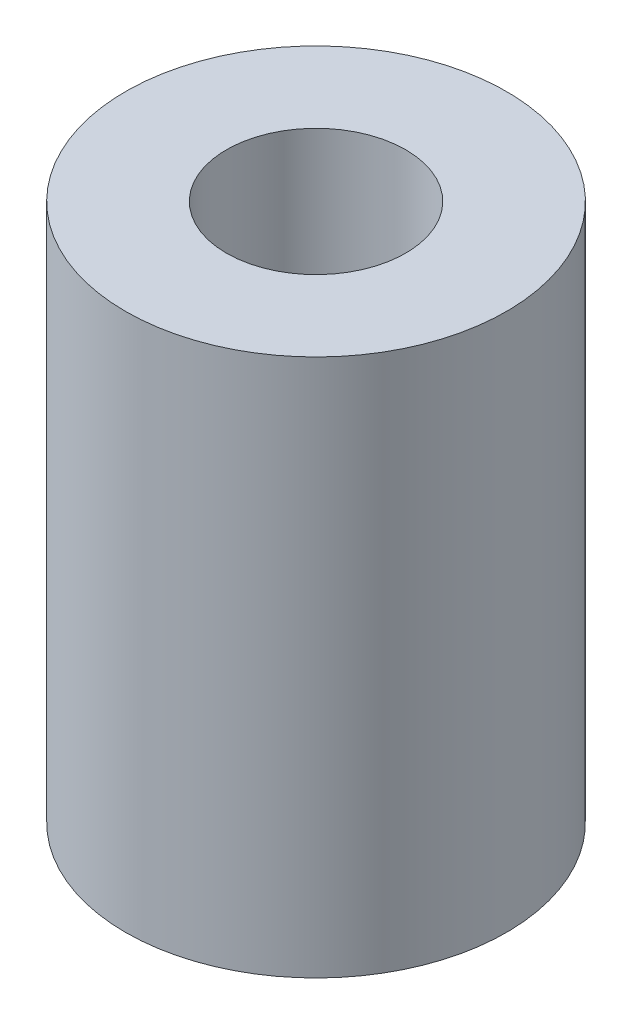
from build123d import *

# Parameters (mm, degrees)
SKETCH1_R           = 2.125
SKETCH1_R_2         = 1
BOSS_EXTRUDE1_DEPTH = 6


with BuildPart() as part:
    # Sketch1 → Boss-Extrude1 (new body)
    with BuildSketch(Plane(origin=(0, 0, 0), x_dir=(1, 0, 0), z_dir=(0, 1, 0))):
        Circle(SKETCH1_R)
        Circle(SKETCH1_R_2, mode=Mode.SUBTRACT)
    extrude(amount=BOSS_EXTRUDE1_DEPTH)


solid = part.part
